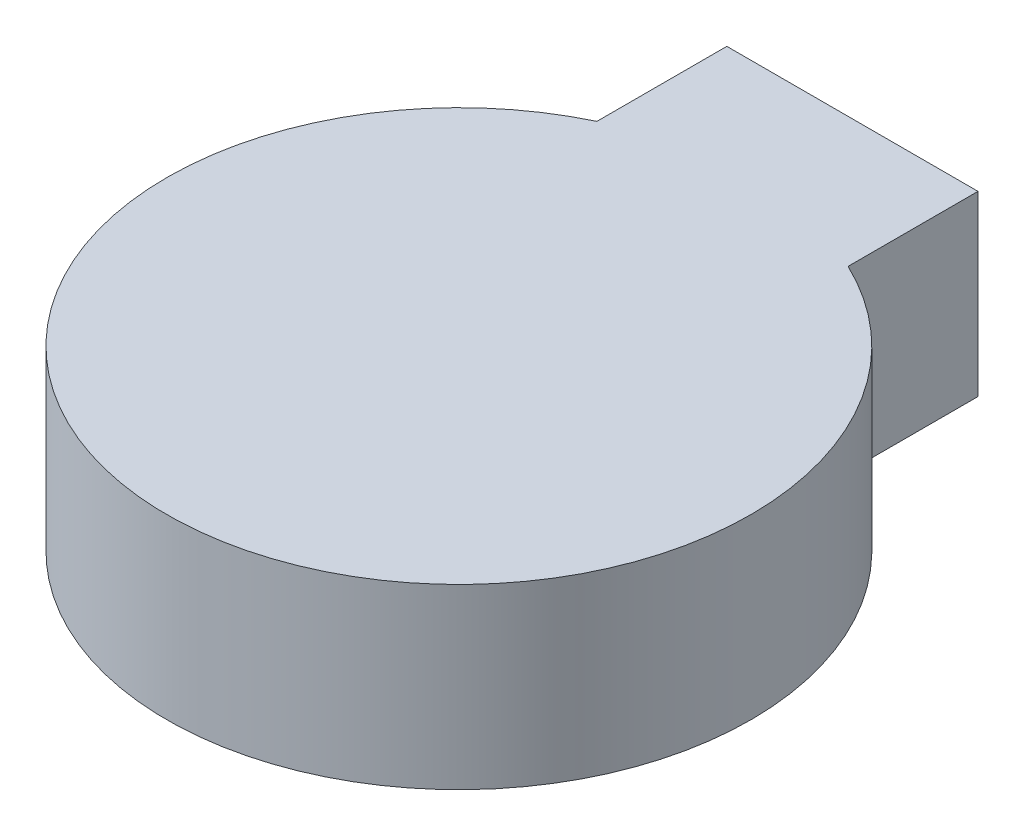
from build123d import *

# Parameters (mm, degrees)
BOSS_EXTRUDE1_DEPTH = 7


with BuildPart() as part:
    # Sketch1 → Boss-Extrude1 (new body)
    with BuildSketch(Plane(origin=(0, 0, 0), x_dir=(1, 0, 0), z_dir=(0, 1, 0))):
        with BuildLine():
            Line((-4.945890924, 15.5), (4.945890924, 15.5))
            Line((4.945890924, 15.5), (4.945890924, 10.382107829))
            ThreePointArc((4.945890924, 10.382107829), (0, -11.5), (-4.945890924, 10.382107829))
            Line((-4.945890924, 10.382107829), (-4.945890924, 15.5))
        make_face()
    extrude(amount=BOSS_EXTRUDE1_DEPTH)


solid = part.part
